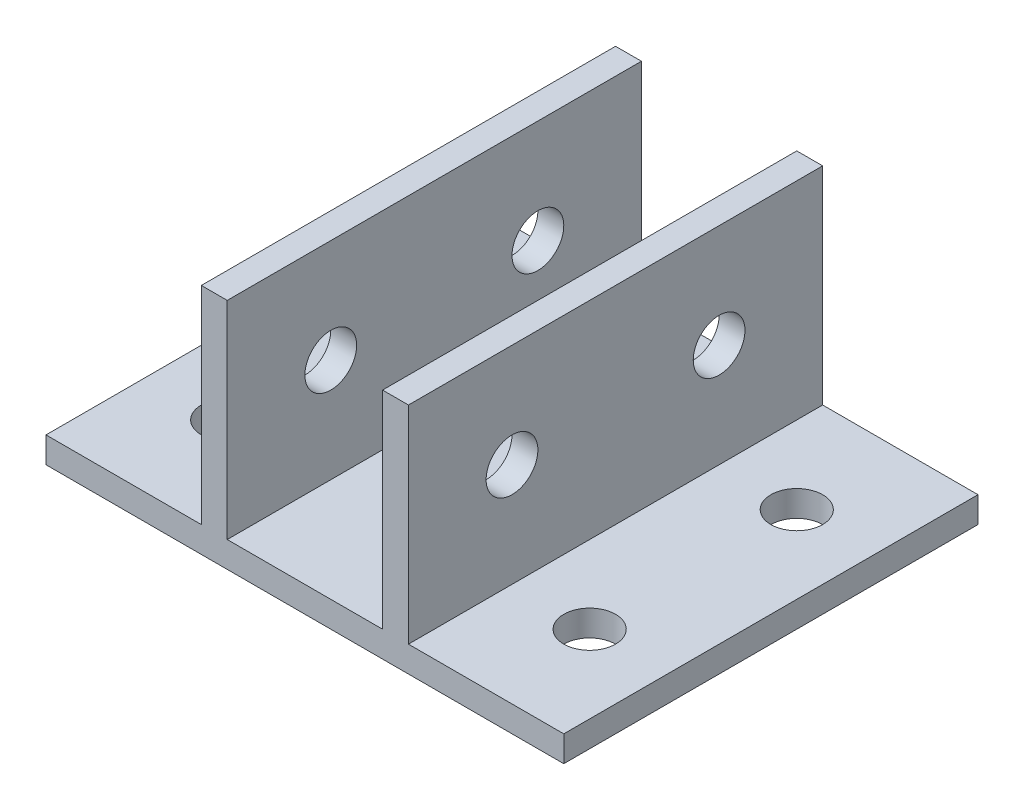
from build123d import *

# Parameters (mm, degrees)
BOSS_EXTRUDE2_DEPTH = 50.8
SKETCH4_R           = 3.175
CUT_EXTRUDE1_DEPTH  = 45.45
SKETCH5_R           = 3.175
CUT_EXTRUDE2_DEPTH  = 4.175


with BuildPart() as part:
    # Sketch3 → Boss-Extrude2 (new body)
    with BuildSketch(Plane.XY):
        Polygon((0, 0), (63.5, 0), (63.5, 3.175), (44.45, 3.175), (44.45, 28.575), (41.275, 28.575), (41.275, 3.175), (22.225, 3.175), (22.225, 28.575), (19.05, 28.575), (19.05, 3.175), (0, 3.175), align=None)
    extrude(amount=BOSS_EXTRUDE2_DEPTH)

    # Sketch4 → Cut-Extrude1 (cut, through all)
    with BuildSketch(Plane.ZY.offset(-19.05)):
        with Locations((12.7, 15.875)):
            Circle(SKETCH4_R)
        with Locations((38.1, 15.875)):
            Circle(SKETCH4_R)
    extrude(amount=-CUT_EXTRUDE1_DEPTH, mode=Mode.SUBTRACT)

    # Sketch5 → Cut-Extrude2 (cut, through all)
    with BuildSketch(Plane(origin=(0, 3.175, 0), x_dir=(1, 0, 0), z_dir=(0, 1, 0))):
        with Locations((9.525, -38.1)):
            Circle(SKETCH5_R)
        with Locations((9.525, -12.7)):
            Circle(SKETCH5_R)
        with Locations((53.975, -12.7)):
            Circle(SKETCH5_R)
        with Locations((53.975, -38.1)):
            Circle(SKETCH5_R)
    extrude(amount=-CUT_EXTRUDE2_DEPTH, mode=Mode.SUBTRACT)


solid = part.part
